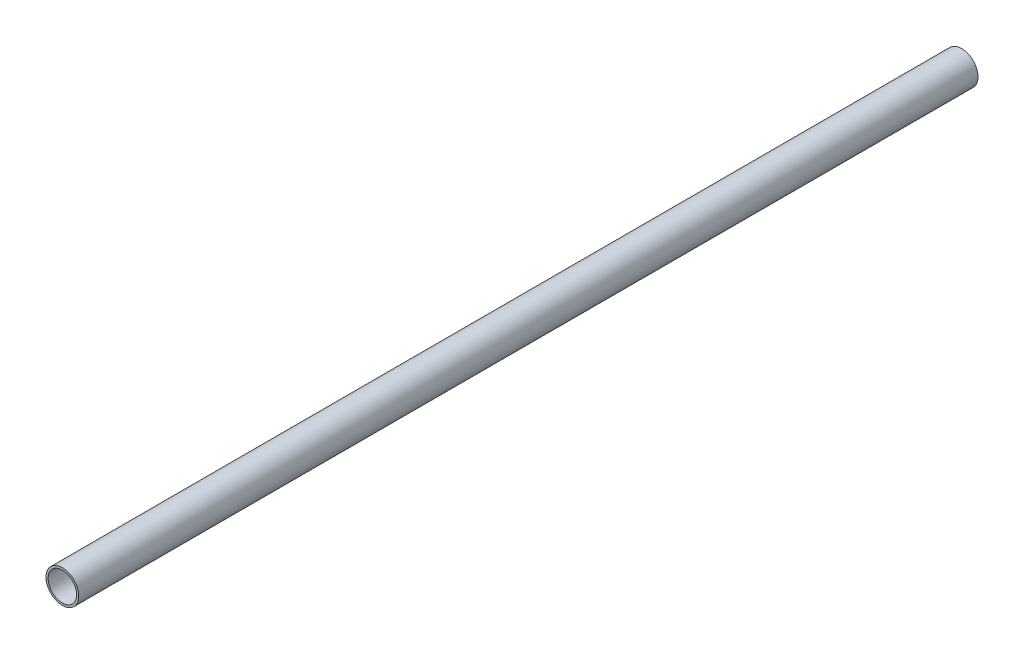
from build123d import *

# Parameters (mm, degrees)
SKETCH1_R           = 44.45
SKETCH1_R_2         = 38.6334
BOSS_EXTRUDE1_DEPTH = 1219.2


with BuildPart() as part:
    # Sketch1 → Boss-Extrude1 (new body, symmetric)
    with BuildSketch(Plane.XY):
        Circle(SKETCH1_R)
        Circle(SKETCH1_R_2, mode=Mode.SUBTRACT)
    extrude(amount=BOSS_EXTRUDE1_DEPTH, both=True)


solid = part.part
